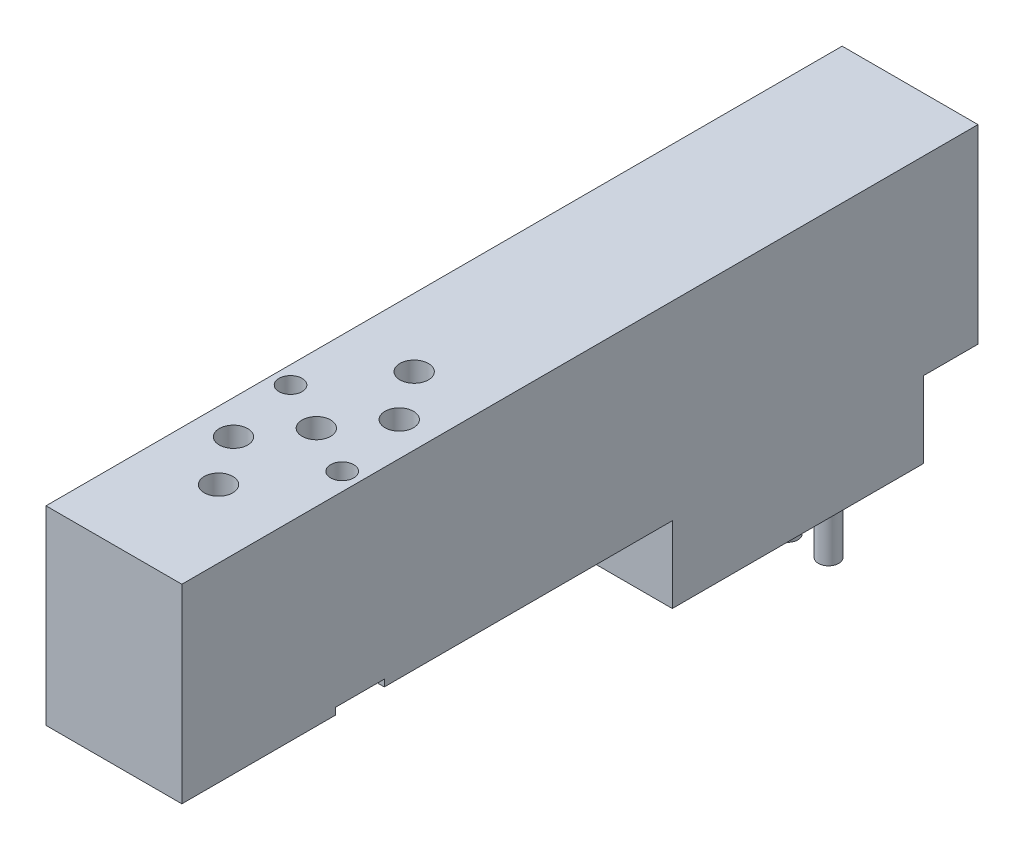
from build123d import *

# Parameters (mm, degrees)
BODY_DEPTH                     = 5
BODY_DEPTH_BACK                = 5
SKETCH2_R                      = 0.85
F_1_7MM_THRU_SCREW_HOLES_DEPTH = 15
SCREWHEAD_RELIEF_DEPTH         = 0.5
SKETCH4_R                      = 1.05
F_1_P_PORT_DEPTH               = 5
SKETCH5_R                      = 1.05
F_2_B_PORT_DEPTH               = 5
SKETCH6_R                      = 1.05
F_3_R2_PORT_DEPTH              = 5
SKETCH7_R                      = 1.05
F_4_A_PORT_DEPTH               = 5
SKETCH8_R                      = 1.05
F_5_R1_PORT_DEPTH              = 5
EXTRUDE3_DEPTH                 = 1
FILLET1_R                      = 0.5
SKETCH10_R                     = 0.75
WIRES_2_DEPTH                  = 5


with BuildPart() as part:
    # Sketch1 → Body (new body, two sides)
    with BuildSketch(Plane(origin=(0, 0, 0), x_dir=(0, 0, -1), z_dir=(1, 0, 0))) as body_sk:
        Polygon((0, 0), (-58.6, 0), (-58.6, -14), (-22.5, -14), (-22.5, -19.6), (-4, -19.6), (-4, -14), (0, -14), align=None)
    extrude(amount=BODY_DEPTH)
    extrude(body_sk.sketch, amount=-BODY_DEPTH_BACK)

    # Sketch2 → 1.7mm Thru Screw Holes (cut, through all)
    with BuildSketch(Plane.XZ.offset(14)):
        with Locations(Location((-3.7, 41.9, 0), (0, 0, 270))):  # turned: the seam where the file's is
            Circle(SKETCH2_R)
        with Locations(Location((3.7, 45.5, 0), (0, 0, 270))):  # turned: the seam where the file's is
            Circle(SKETCH2_R)
    extrude(amount=-F_1_7MM_THRU_SCREW_HOLES_DEPTH, mode=Mode.SUBTRACT)

    # Sketch3 → Screwhead Relief (cut)
    with BuildSketch(Plane.XZ.offset(14)):
        with BuildLine():
            Line((-3.7, 43.7), (-5, 43.7))
            Line((-5, 43.7), (-5, 40.1))
            Line((-5, 40.1), (-3.7, 40.1))
            ThreePointArc((-3.7, 40.1), (-1.9, 41.9), (-3.7, 43.7))
        make_face()
        with BuildLine():
            Line((3.7, 47.3), (5, 47.3))
            Line((5, 47.3), (5, 43.7))
            Line((5, 43.7), (3.7, 43.7))
            ThreePointArc((3.7, 43.7), (1.9, 45.5), (3.7, 47.3))
        make_face()
    extrude(amount=-SCREWHEAD_RELIEF_DEPTH, mode=Mode.SUBTRACT)

    # Sketch4 → 1 P _port (cut)
    with BuildSketch(Plane(origin=(0, 0, 0), x_dir=(-1, 0, 0), z_dir=(0, 1, 0))):
        with Locations(Location((0, 43.7, 0), (0, 0, 90))):  # turned: the seam where the file's is
            Circle(SKETCH4_R)
    extrude(amount=-F_1_P_PORT_DEPTH, mode=Mode.SUBTRACT)

    # Sketch5 → 2 B _port (cut)
    with BuildSketch(Plane(origin=(0, 0, 0), x_dir=(-1, 0, 0), z_dir=(0, 1, 0))):
        with Locations(Location((2.5, 47.3, 0), (0, 0, 90))):  # turned: the seam where the file's is
            Circle(SKETCH5_R)
    extrude(amount=-F_2_B_PORT_DEPTH, mode=Mode.SUBTRACT)

    # Sketch6 → 3 R2 _port (cut)
    with BuildSketch(Plane(origin=(0, 0, 0), x_dir=(-1, 0, 0), z_dir=(0, 1, 0))):
        with Locations(Location((0, 50.9, 0), (0, 0, 90))):  # turned: the seam where the file's is
            Circle(SKETCH6_R)
    extrude(amount=-F_3_R2_PORT_DEPTH, mode=Mode.SUBTRACT)

    # Sketch7 → 4 A _port (cut)
    with BuildSketch(Plane(origin=(0, 0, 0), x_dir=(-1, 0, 0), z_dir=(0, 1, 0))):
        with Locations(Location((-2.5, 40.1, 0), (0, 0, 90))):  # turned: the seam where the file's is
            Circle(SKETCH7_R)
    extrude(amount=-F_4_A_PORT_DEPTH, mode=Mode.SUBTRACT)

    # Sketch8 → 5 R1 _port (cut)
    with BuildSketch(Plane(origin=(0, 0, 0), x_dir=(-1, 0, 0), z_dir=(0, 1, 0))):
        with Locations(Location((0, 36.5, 0), (0, 0, 90))):  # turned: the seam where the file's is
            Circle(SKETCH8_R)
    extrude(amount=-F_5_R1_PORT_DEPTH, mode=Mode.SUBTRACT)

    # Sketch9 → Extrude3 (add)
    with BuildSketch(Plane.XZ.offset(19.6)):
        with BuildLine():
            Line((-1.5, 9.5), (1.5, 9.5))
            ThreePointArc((1.5, 9.5), (3.5, 7.5), (1.5, 5.5))
            Line((1.5, 5.5), (-1.5, 5.5))
            ThreePointArc((-1.5, 5.5), (-3.5, 7.5), (-1.5, 9.5))
        make_face()
    extrude(amount=EXTRUDE3_DEPTH)

    # Fillet1
    fillet1_edges = [part.edges().sort_by_distance(p)[0] for p in [
        (-3.5, -20.6, 7.5),
        (0, -20.6, 5.5),
        (3.5, -20.6, 7.5),
        (0, -20.6, 9.5),
    ]]
    fillet(fillet1_edges, radius=FILLET1_R)

    # Sketch10 → Wires 2 (add)
    with BuildSketch(Plane.XZ.offset(20.6)):
        with Locations(Location((-1.5, 7.5, 0), (0, 0, 270))):  # turned: the seam where the file's is
            Circle(SKETCH10_R)
        with Locations(Location((1.5, 7.5, 0), (0, 0, 270))):  # turned: the seam where the file's is
            Circle(SKETCH10_R)
    extrude(amount=WIRES_2_DEPTH)


solid = part.part
